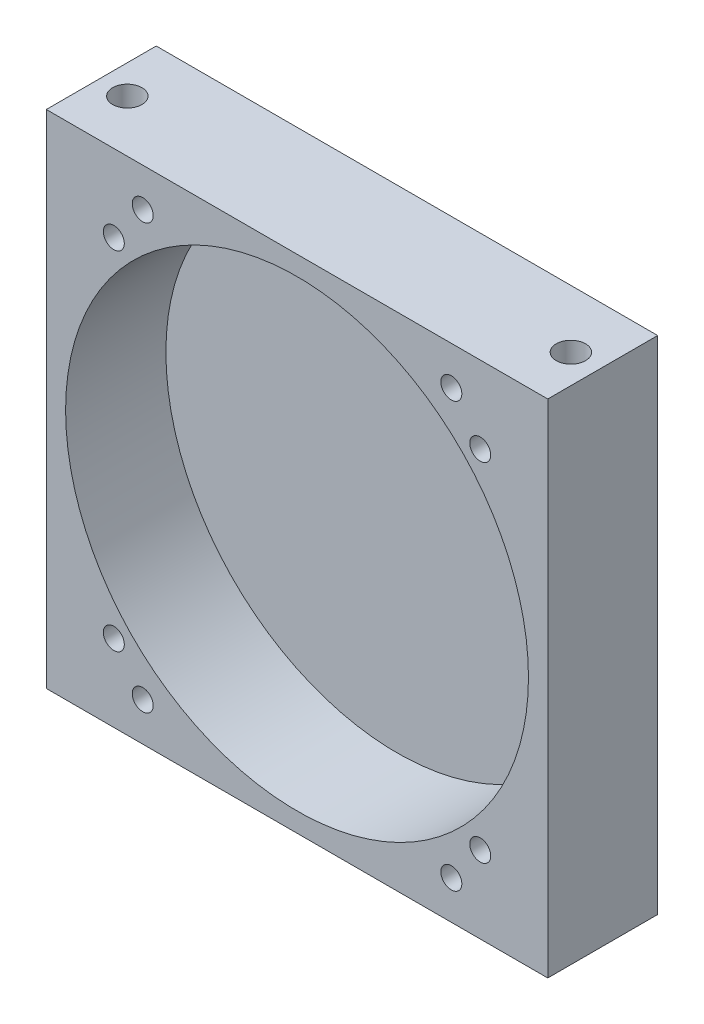
from build123d import *

# Parameters (mm, degrees)
SKETCH1_W                       = 82.55
SKETCH1_H                       = 82.55
BOSS_EXTRUDE1_DEPTH             = 18.0975
SKETCH2_R                       = 38.1
CUT_EXTRUDE1_DEPTH              = 16.51
F_10_32_TAPPED_HOLE1_AT_2_COUNT = 2
F_10_32_TAPPED_HOLE1_AT_2_PITCH = 73.025
F_8_32_TAPPED_HOLE1_D           = 3.4544
F_8_32_TAPPED_HOLE1_DEPTH       = 16.002
F_8_32_TAPPED_HOLE1_TIP         = 1.037806461
F_8_32_TAPPED_HOLE2_D           = 3.4544
F_8_32_TAPPED_HOLE2_DEPTH       = 16.002
F_8_32_TAPPED_HOLE2_TIP         = 1.037806461


with BuildPart() as part:
    # Sketch1 → Boss-Extrude1 (new body)
    with BuildSketch(Plane.XY):
        Rectangle(SKETCH1_W, SKETCH1_H)
    extrude(amount=BOSS_EXTRUDE1_DEPTH)

    # Sketch2 → Cut-Extrude1 (cut)
    with BuildSketch(Plane.XY.offset(18.0975)):
        Circle(SKETCH2_R)
    extrude(amount=-CUT_EXTRUDE1_DEPTH, mode=Mode.SUBTRACT)

    # Sketch3 → #10-32 Tapped Hole1 (revolve, cut)
    with BuildSketch(Plane(origin=(-36.5125, 41.275, 9.525), x_dir=(0, 0, 1), z_dir=(1, 0, 0))):
        Polygon((0, 0), (0, 20.263317848), (2.0193, 19.05), (2.0193, 18.288), (2.413, 18.288), (2.413, 0), align=None)
    f_10_32_tapped_hole1 = revolve(axis=Axis((-36.5125, 47.625, 9.525), (0, -1, 0)), mode=Mode.SUBTRACT)

    # #10-32 Tapped Hole1 at 2: #10-32 Tapped Hole1 ×2
    with Locations(*[(i * F_10_32_TAPPED_HOLE1_AT_2_PITCH, 0, 0) for i in range(1, F_10_32_TAPPED_HOLE1_AT_2_COUNT)]):
        add(f_10_32_tapped_hole1, mode=Mode.SUBTRACT)

    # Mirror1: #10-32 Tapped Hole1 across plane
    add(f_10_32_tapped_hole1.mirror(Plane.ZX), mode=Mode.SUBTRACT)

    # Mirror1 copy 1 sketch → Mirror1 copy 1 (revolve, cut)
    with BuildSketch(Plane(origin=(36.5125, -41.275, 9.525), x_dir=(0, 0, 1), z_dir=(1, 0, 0))):
        Polygon((0, 0), (0, -20.263317848), (2.0193, -19.05), (2.0193, -18.288), (2.413, -18.288), (2.413, 0), align=None)
    revolve(axis=Axis((36.5125, -47.625, 9.525), (0, -1, 0)), mode=Mode.SUBTRACT)

    # #8-32 Tapped Hole1
    with Locations(Plane.XY.offset(18.0975)):
        with Locations((25.4, -34.925), (-25.4, -34.925), (-25.4, 34.925), (25.4, 34.925)):
            Hole(F_8_32_TAPPED_HOLE1_D / 2, depth=F_8_32_TAPPED_HOLE1_DEPTH)
            with Locations((0, 0, -(F_8_32_TAPPED_HOLE1_DEPTH + F_8_32_TAPPED_HOLE1_TIP / 2))):  # 118° drill point
                Cone(0, F_8_32_TAPPED_HOLE1_D / 2, F_8_32_TAPPED_HOLE1_TIP, mode=Mode.SUBTRACT)

    # #8-32 Tapped Hole2
    with Locations(Plane.XY.offset(18.0975)):
        with Locations((30.1625, -28.575), (-30.1625, 28.575), (-30.1625, -28.575), (30.1625, 28.575)):
            Hole(F_8_32_TAPPED_HOLE2_D / 2, depth=F_8_32_TAPPED_HOLE2_DEPTH)
            with Locations((0, 0, -(F_8_32_TAPPED_HOLE2_DEPTH + F_8_32_TAPPED_HOLE2_TIP / 2))):  # 118° drill point
                Cone(0, F_8_32_TAPPED_HOLE2_D / 2, F_8_32_TAPPED_HOLE2_TIP, mode=Mode.SUBTRACT)


solid = part.part
